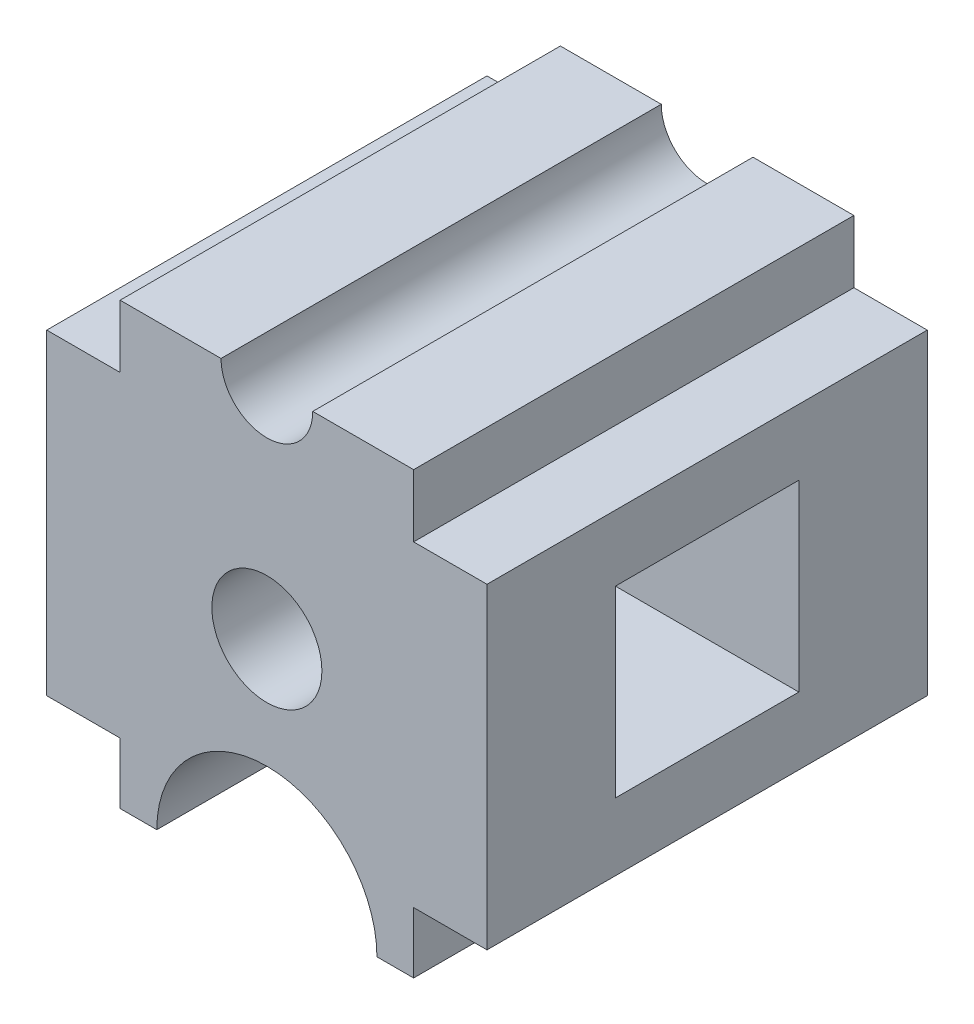
from build123d import *

# Parameters (mm, degrees)
SKETCH1_R           = 15
BOSS_EXTRUDE1_DEPTH = 60
SKETCH2_W           = 50
SKETCH2_H           = 50
CUT_EXTRUDE1_DEPTH  = 120


with BuildPart() as part:
    # Sketch1 → Boss-Extrude1 (new body, symmetric)
    with BuildSketch(Plane.XY):
        with BuildLine():
            Line((30, -60), (40, -60))
            Line((40, -60), (40, -43.369403571))
            Line((40, -43.369403571), (60, -43.369403571))
            Line((60, -43.369403571), (60, 42.942577675))
            Line((60, 42.942577675), (40, 42.942577675))
            Line((40, 42.942577675), (40, 60))
            Line((40, 60), (12.5, 60))
            ThreePointArc((12.5, 60), (0, 47.5), (-12.5, 60))
            Line((-12.5, 60), (-40, 60))
            Line((-40, 60), (-40, 42.942577675))
            Line((-40, 42.942577675), (-60, 42.942577675))
            Line((-60, 42.942577675), (-60, 0))
            Line((-60, 0), (-60, -43.369403571))
            Line((-60, -43.369403571), (-40, -43.369403571))
            Line((-40, -43.369403571), (-40, -60))
            Line((-40, -60), (-30, -60))
            ThreePointArc((-30, -60), (0, -30), (30, -60))
        make_face()
        Circle(SKETCH1_R, mode=Mode.SUBTRACT)
    extrude(amount=BOSS_EXTRUDE1_DEPTH, both=True)

    # Sketch2 → Cut-Extrude1 (cut)
    with BuildSketch(Plane(origin=(60, 0, 0), x_dir=(0, 0, -1), z_dir=(1, 0, 0))):
        Rectangle(SKETCH2_W, SKETCH2_H)
    extrude(amount=-CUT_EXTRUDE1_DEPTH, mode=Mode.SUBTRACT)


solid = part.part
